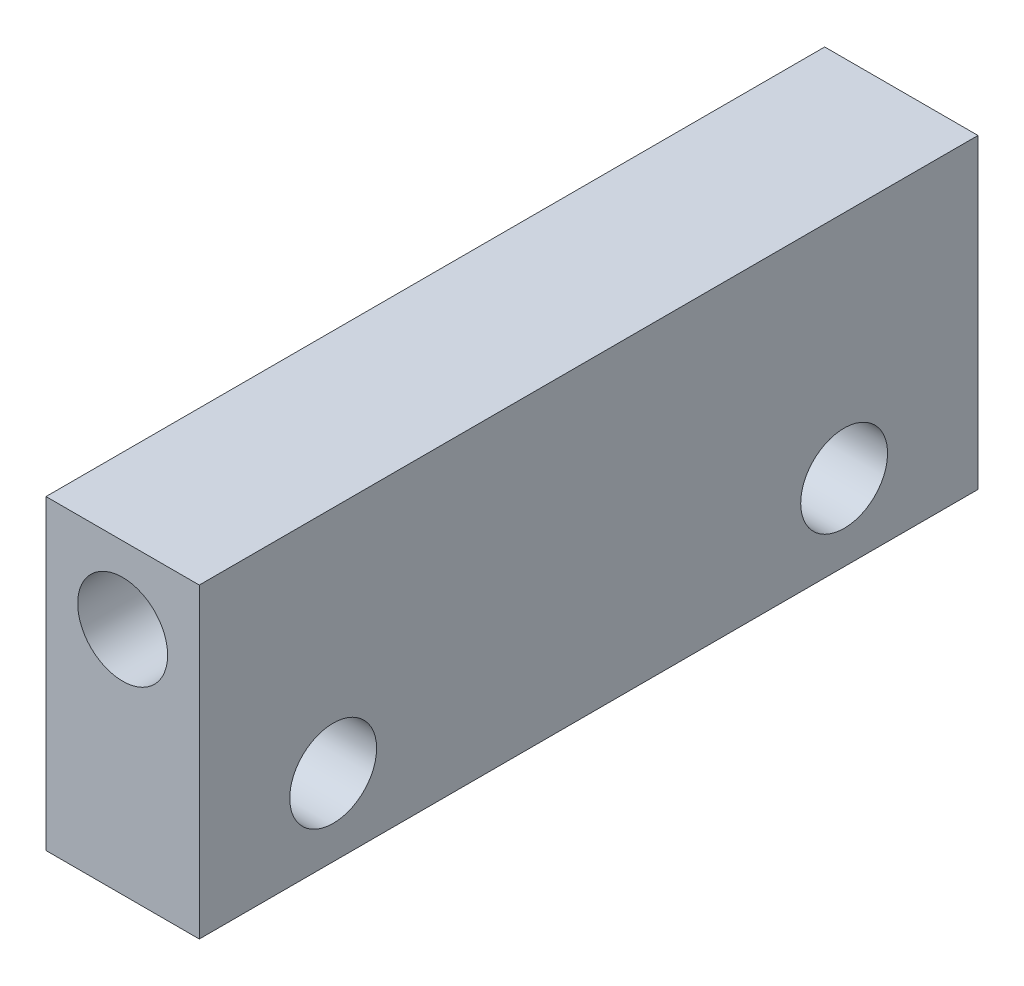
from build123d import *

# Parameters (mm, degrees)
SKETCH2_W           = 15
SKETCH2_H           = 30
SKETCH2_R           = 4.4
BOSS_EXTRUDE1_DEPTH = 76.2
SKETCH3_R           = 4.25
CUT_EXTRUDE2_DEPTH  = 16


with BuildPart() as part:
    # Sketch2 → Boss-Extrude1 (new body)
    with BuildSketch(Plane.XY):
        with Locations((-10.953990987, 24.19276181)):
            Rectangle(SKETCH2_W, SKETCH2_H)
        with Locations((-10.953990987, 31.69276181)):
            Circle(SKETCH2_R, mode=Mode.SUBTRACT)
    extrude(amount=BOSS_EXTRUDE1_DEPTH)

    # Sketch3 → Cut-Extrude2 (cut, through all)
    with BuildSketch(Plane(origin=(-3.453990987, 0, 0), x_dir=(0, 0, -1), z_dir=(1, 0, 0))):
        with Locations((-63.1, 16.69276181)):
            Circle(SKETCH3_R)
        with Locations((-13.1, 16.69276181)):
            Circle(SKETCH3_R)
    extrude(amount=-CUT_EXTRUDE2_DEPTH, mode=Mode.SUBTRACT)


solid = part.part
